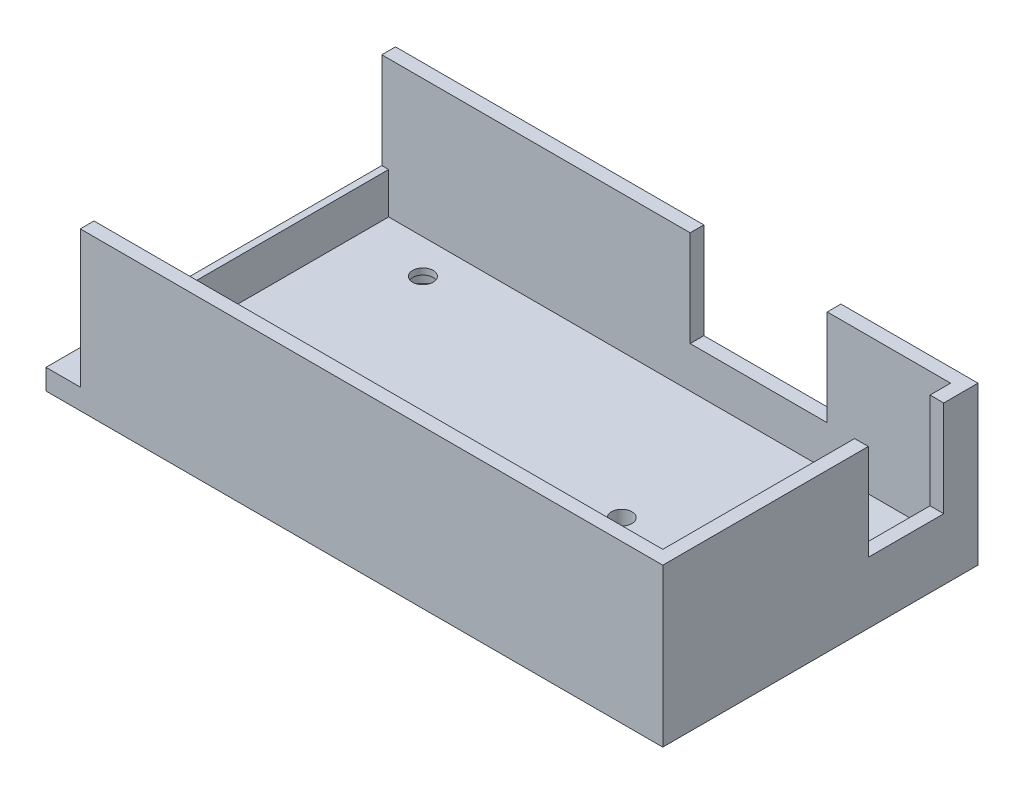
from build123d import *

# Parameters (mm, degrees)
SKETCH1_W           = 90
SKETCH1_H           = 46
BOSS_EXTRUDE1_DEPTH = 3
SKETCH5_R           = 1.5
CUT_EXTRUDE3_DEPTH  = 4
SKETCH6_W           = 2
SKETCH6_H           = 28
SKETCH6_W_2         = 60
SKETCH6_H_2         = 2
SKETCH6_H_3         = 3
SKETCH6_W_3         = 45
BOSS_EXTRUDE3_DEPTH = 20
SKETCH7_R           = 1.5
CUT_EXTRUDE4_DEPTH  = 4
SKETCH8_R           = 3
CUT_EXTRUDE5_DEPTH  = 2.1
SKETCH9_W           = 2
SKETCH9_H           = 11
SKETCH9_W_2         = 20
SKETCH9_H_2         = 2
SKETCH9_W_3         = 1
SKETCH9_H_3         = 42
BOSS_EXTRUDE4_DEPTH = 6


with BuildPart() as part:
    # Sketch1 → Boss-Extrude1 (new body)
    with BuildSketch(Plane(origin=(0, 0, 0), x_dir=(1, 0, 0), z_dir=(0, 1, 0))):
        with Locations((-15.229105331, -10.267137121)):
            Rectangle(SKETCH1_W, SKETCH1_H)
    extrude(amount=BOSS_EXTRUDE1_DEPTH)

    # Sketch5 → Cut-Extrude3 (cut, through all)
    with BuildSketch(Plane(origin=(0, 3, 0), x_dir=(1, 0, 0), z_dir=(0, 1, 0))):
        with Locations((-57.229105331, -22.267137121)):
            Circle(SKETCH5_R)
        with Locations((-57.229105331, 1.732862879)):
            Circle(SKETCH5_R)
        with Locations((0.770894669, -10.267137121)):
            Circle(SKETCH5_R)
    extrude(amount=-CUT_EXTRUDE3_DEPTH, mode=Mode.SUBTRACT)

    # Sketch6 → Boss-Extrude3 (add)
    with BuildSketch(Plane(origin=(0, 3, 0), x_dir=(1, 0, 0), z_dir=(0, 1, 0))):
        with Locations((28.770894669, -17.267137121)):
            Rectangle(SKETCH6_W, SKETCH6_H)
        Polygon((29.770894669, -31.267137121), (27.770894669, -31.267137121), (4.770894669, -31.267137121), (4.770894669, -33.267137121), (29.770894669, -33.267137121), align=None)
        with Locations((-25.229105331, -32.267137121)):
            Rectangle(SKETCH6_W_2, SKETCH6_H_2)
        with Locations((28.770894669, 9.232862879)):
            Rectangle(SKETCH6_W, SKETCH6_H_3)
        Polygon((9.770894669, 10.732862879), (27.770894669, 10.732862879), (29.770894669, 10.732862879), (29.770894669, 12.732862879), (9.770894669, 12.732862879), align=None)
        with Locations((-32.729105331, 11.732862879)):
            Rectangle(SKETCH6_W_3, SKETCH6_H_2)
    extrude(amount=BOSS_EXTRUDE3_DEPTH)

    # Sketch7 → Cut-Extrude4 (cut, through all)
    with BuildSketch(Plane(origin=(0, 3, 0), x_dir=(1, 0, 0), z_dir=(0, 1, 0))):
        with Locations((15.770894669, -26.267137121)):
            Circle(SKETCH7_R)
        with Locations((-44.229105331, -26.267137121)):
            Circle(SKETCH7_R)
        with Locations((15.770894669, 5.732862879)):
            Circle(SKETCH7_R)
        with Locations((-44.229105331, 5.732862879)):
            Circle(SKETCH7_R)
    extrude(amount=-CUT_EXTRUDE4_DEPTH, mode=Mode.SUBTRACT)

    # Sketch8 → Cut-Extrude5 (cut)
    with BuildSketch(Plane(origin=(0, 0, 0), x_dir=(-1, 0, 0), z_dir=(0, -1, 0))):
        with Locations((-15.770894669, -26.267137121)):
            Circle(SKETCH8_R)
        with Locations((-15.770894669, 5.732862879)):
            Circle(SKETCH8_R)
        with Locations((44.229105331, -26.267137121)):
            Circle(SKETCH8_R)
        with Locations((44.229105331, 5.732862879)):
            Circle(SKETCH8_R)
    extrude(amount=-CUT_EXTRUDE5_DEPTH, mode=Mode.SUBTRACT)

    # Sketch9 → Boss-Extrude4 (add)
    with BuildSketch(Plane(origin=(0, 3, 0), x_dir=(1, 0, 0), z_dir=(0, 1, 0))):
        with Locations((28.770894669, 2.232862879)):
            Rectangle(SKETCH9_W, SKETCH9_H)
        with Locations((-0.229105331, 11.732862879)):
            Rectangle(SKETCH9_W_2, SKETCH9_H_2)
        with Locations((-54.729105331, -10.267137121)):
            Rectangle(SKETCH9_W_3, SKETCH9_H_3)
    extrude(amount=BOSS_EXTRUDE4_DEPTH)


solid = part.part
